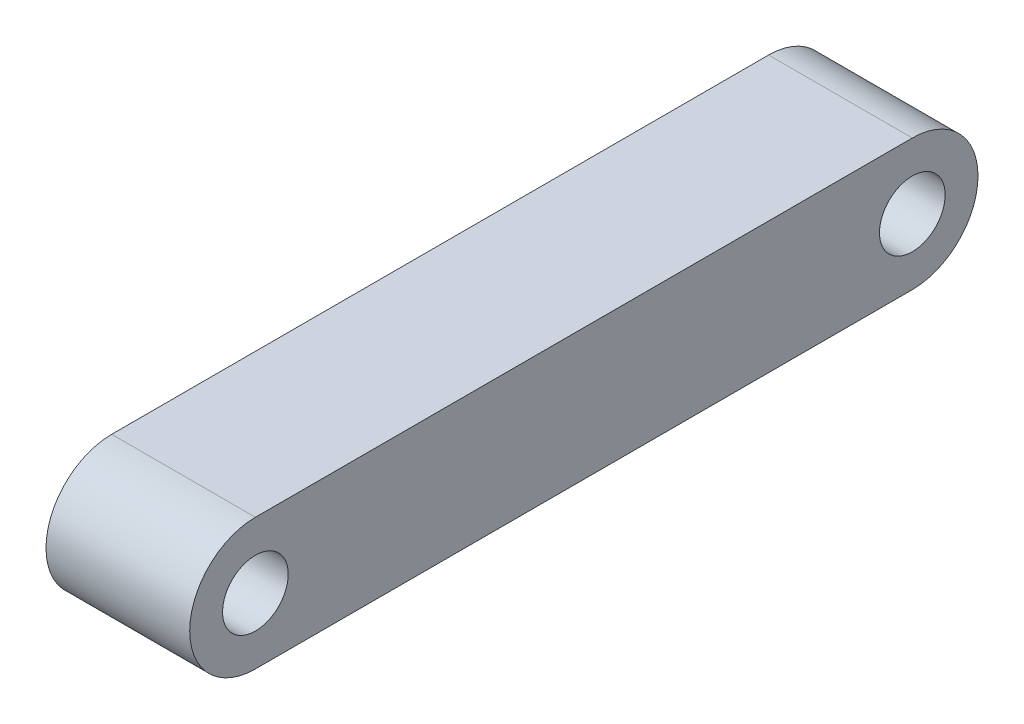
from build123d import *

# Parameters (mm, degrees)
SKETCH_1_R      = 4
EXTRUDE_1_DEPTH = 17.5


with BuildPart() as part:
    # 草图1 → 凸台-拉伸1 (new body)
    with BuildSketch(Plane(origin=(0, 0, 0), x_dir=(0, 0, -1), z_dir=(1, 0, 0))):
        with BuildLine():
            Line((-40, 8), (40, 8))
            ThreePointArc((40, 8), (48, 0), (40, -8))
            Line((40, -8), (-40, -8))
            ThreePointArc((-40, -8), (-48, 0), (-40, 8))
        make_face()
        with Locations((40, 0)):
            Circle(SKETCH_1_R, mode=Mode.SUBTRACT)
        with Locations((-40, 0)):
            Circle(SKETCH_1_R, mode=Mode.SUBTRACT)
    extrude(amount=EXTRUDE_1_DEPTH)


solid = part.part
